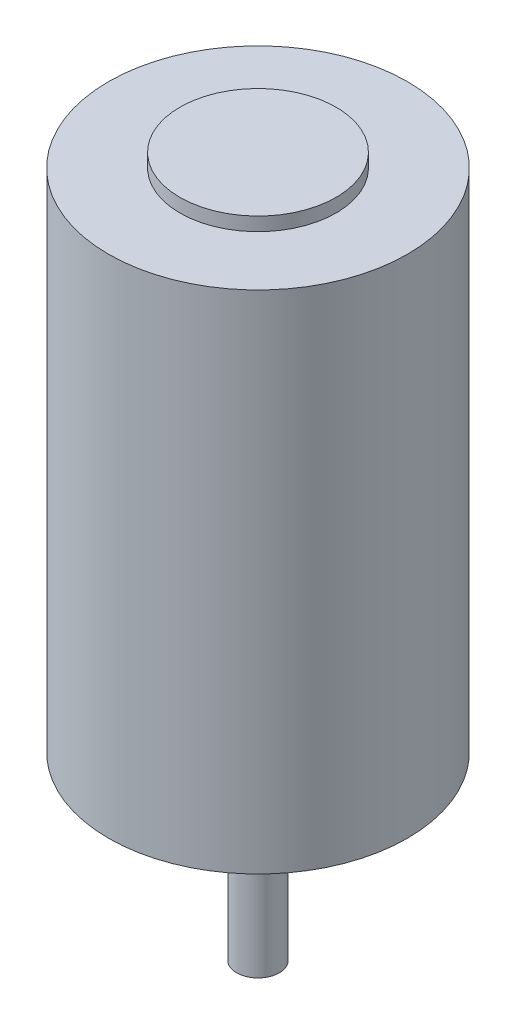
from build123d import *

# Parameters (mm, degrees)
SKETCH2_R           = 21.0185
BOSS_EXTRUDE1_DEPTH = 71.12
SKETCH3_R           = 10.9855
BOSS_EXTRUDE2_DEPTH = 1.905
SKETCH4_R           = 10.9855
SKETCH4_R_2         = 8.4455
BOSS_EXTRUDE3_DEPTH = 1.905
SKETCH5_R           = 3
BOSS_EXTRUDE4_DEPTH = 25.4
SKETCH6_R           = 5.08
BOSS_EXTRUDE5_DEPTH = 3.429
SKETCH7_R           = 1.27
CUT_EXTRUDE1_DEPTH  = 5.08


with BuildPart() as part:
    # Sketch2 → Boss-Extrude1 (new body)
    with BuildSketch(Plane(origin=(0, 0, 0), x_dir=(1, 0, 0), z_dir=(0, 1, 0))):
        Circle(SKETCH2_R)
    extrude(amount=BOSS_EXTRUDE1_DEPTH)

    # Sketch3 → Boss-Extrude2 (add)
    with BuildSketch(Plane(origin=(0, 71.12, 0), x_dir=(1, 0, 0), z_dir=(0, 1, 0))):
        Circle(SKETCH3_R)
    extrude(amount=BOSS_EXTRUDE2_DEPTH)

    # Sketch4 → Boss-Extrude3 (add)
    with BuildSketch(Plane.XZ):
        Circle(SKETCH4_R)
        Circle(SKETCH4_R_2, mode=Mode.SUBTRACT)
    extrude(amount=BOSS_EXTRUDE3_DEPTH)

    # Sketch5 → Boss-Extrude4 (add)
    with BuildSketch(Plane.XZ):
        Circle(SKETCH5_R)
    extrude(amount=BOSS_EXTRUDE4_DEPTH)

    # Sketch6 → Boss-Extrude5 (add)
    with BuildSketch(Plane.XZ):
        Circle(SKETCH6_R)
    extrude(amount=BOSS_EXTRUDE5_DEPTH)

    # Sketch7 → Cut-Extrude1 (cut)
    with BuildSketch(Plane.XZ):
        with Locations((15.875, 0)):
            Circle(SKETCH7_R)
        with Locations((-15.875, 0)):
            Circle(SKETCH7_R)
    extrude(amount=-CUT_EXTRUDE1_DEPTH, mode=Mode.SUBTRACT)


solid = part.part
